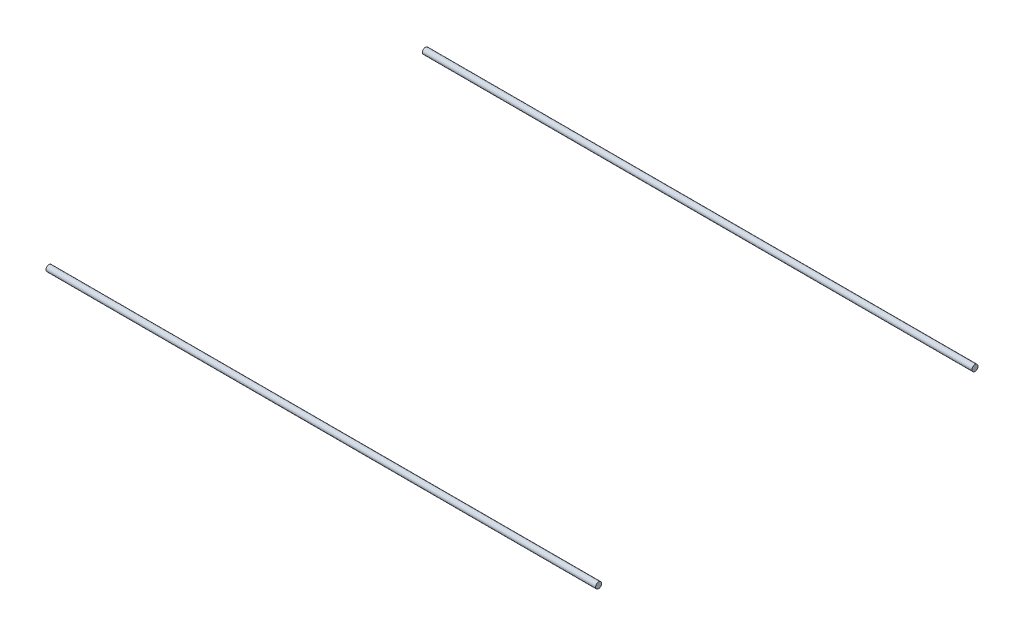
from build123d import *

# Parameters (mm, degrees)
BOSS_EXTRUDE1_DEPTH   = 265
BOSS_EXTRUDE1_2_DEPTH = 265
BOSS_EXTRUDE2_DEPTH   = 335
SKETCH16_R            = 4
BOSS_EXTRUDE3_DEPTH   = 730
BOSS_EXTRUDE3_2_DEPTH = 730


with BuildPart() as part:
    # Sketch13 → Boss-Extrude1 (new, symmetric)
    with BuildSketch(Plane.XY):
        with BuildLine():
            Line((356.00446543, 0.899999619), (355.484852164, 0))
            Line((355.484852164, 0), (356.00446543, -0.899999619))
            Line((356.00446543, -0.899999619), (356.00446543, -4.204465866))
            Line((356.00446543, -4.204465866), (360.049999564, -8.25))
            Line((360.049999564, -8.25), (362.59999928, -8.25))
            ThreePointArc((362.59999928, -8.25), (362.741420837, -8.191421273), (362.799999564, -8.049999716))
            Line((362.799999564, -8.049999716), (362.799999564, -4.649999613))
            ThreePointArc((362.799999564, -4.649999613), (362.975735606, -4.225735278), (363.39999994, -4.049999237))
            Line((363.39999994, -4.049999237), (364.300000043, -4.049999237))
            ThreePointArc((364.300000043, -4.049999237), (364.4414216, -4.108577964), (364.500000327, -4.249999521))
            Line((364.500000327, -4.249999521), (364.500000327, -4.349998953))
            ThreePointArc((364.500000327, -4.349998953), (364.558579054, -4.49142051), (364.700000611, -4.549999237))
            Line((364.700000611, -4.549999237), (364.799999716, -4.549999237))
            ThreePointArc((364.799999716, -4.549999237), (364.941421273, -4.608577964), (365, -4.749999521))
            Line((365, -4.749999521), (365, -13.000000346))
            ThreePointArc((365, -13.000000346), (364.414213664, -14.414213664), (363.000000346, -15))
            Line((363.000000346, -15), (354.749999945, -15))
            ThreePointArc((354.749999945, -15), (354.60857832, -14.941421245), (354.549999564, -14.799999619))
            Line((354.549999564, -14.799999619), (354.549999564, -14.69999942))
            ThreePointArc((354.549999564, -14.69999942), (354.49142109, -14.558578474), (354.350000144, -14.5))
            Line((354.350000144, -14.5), (354.250000374, -14.5))
            ThreePointArc((354.250000374, -14.5), (354.108578753, -14.441421247), (354.05, -14.299999626))
            Line((354.05, -14.299999626), (354.05, -13.399999434))
            ThreePointArc((354.05, -13.399999434), (354.225735989, -12.975735226), (354.650000197, -12.799999237))
            Line((354.650000197, -12.799999237), (358.049999924, -12.799999237))
            ThreePointArc((358.049999924, -12.799999237), (358.191421565, -12.741420475), (358.250000327, -12.599998834))
            Line((358.250000327, -12.599998834), (358.250000327, -10.049999237))
            Line((358.250000327, -10.049999237), (354.204466193, -6))
            Line((354.204466193, -6), (350.899999946, -6))
            Line((350.899999946, -6), (350, -5.484851837))
            Line((350, -5.484851837), (349.100000054, -6))
            Line((349.100000054, -6), (345.795533807, -6))
            Line((345.795533807, -6), (341.749999673, -10.049999237))
            Line((341.749999673, -10.049999237), (341.749999673, -12.599998834))
            ThreePointArc((341.749999673, -12.599998834), (341.808578435, -12.741420475), (341.950000076, -12.799999237))
            Line((341.950000076, -12.799999237), (345.349999803, -12.799999237))
            ThreePointArc((345.349999803, -12.799999237), (345.774264011, -12.975735226), (345.95, -13.399999434))
            Line((345.95, -13.399999434), (345.95, -14.299999626))
            ThreePointArc((345.95, -14.299999626), (345.891421247, -14.441421247), (345.749999626, -14.5))
            Line((345.749999626, -14.5), (345.649999856, -14.5))
            ThreePointArc((345.649999856, -14.5), (345.50857891, -14.558578474), (345.450000436, -14.69999942))
            Line((345.450000436, -14.69999942), (345.450000436, -14.799999619))
            ThreePointArc((345.450000436, -14.799999619), (345.39142168, -14.941421245), (345.250000055, -15))
            Line((345.250000055, -15), (336.999999654, -15))
            ThreePointArc((336.999999654, -15), (335.585786336, -14.414213664), (335, -13.000000346))
            Line((335, -13.000000346), (335, -4.749999521))
            ThreePointArc((335, -4.749999521), (335.058578727, -4.608577964), (335.200000284, -4.549999237))
            Line((335.200000284, -4.549999237), (335.299999389, -4.549999237))
            ThreePointArc((335.299999389, -4.549999237), (335.441420946, -4.49142051), (335.499999673, -4.349998953))
            Line((335.499999673, -4.349998953), (335.499999673, -4.249999521))
            ThreePointArc((335.499999673, -4.249999521), (335.5585784, -4.108577964), (335.699999957, -4.049999237))
            Line((335.699999957, -4.049999237), (336.60000006, -4.049999237))
            ThreePointArc((336.60000006, -4.049999237), (337.024264394, -4.225735278), (337.200000436, -4.649999613))
            Line((337.200000436, -4.649999613), (337.200000436, -8.049999716))
            ThreePointArc((337.200000436, -8.049999716), (337.258579163, -8.191421273), (337.40000072, -8.25))
            Line((337.40000072, -8.25), (339.950000436, -8.25))
            Line((339.950000436, -8.25), (343.99553457, -4.204465866))
            Line((343.99553457, -4.204465866), (343.99553457, -0.899999619))
            Line((343.99553457, -0.899999619), (344.515147836, 0))
            Line((344.515147836, 0), (343.99553457, 0.899999619))
            Line((343.99553457, 0.899999619), (343.99553457, 4.204465866))
            Line((343.99553457, 4.204465866), (339.950000436, 8.25))
            Line((339.950000436, 8.25), (337.40000072, 8.25))
            ThreePointArc((337.40000072, 8.25), (337.258579163, 8.191421273), (337.200000436, 8.049999716))
            Line((337.200000436, 8.049999716), (337.200000436, 4.649999613))
            ThreePointArc((337.200000436, 4.649999613), (337.024264394, 4.225735278), (336.60000006, 4.049999237))
            Line((336.60000006, 4.049999237), (335.699999957, 4.049999237))
            ThreePointArc((335.699999957, 4.049999237), (335.5585784, 4.108577964), (335.499999673, 4.249999521))
            Line((335.499999673, 4.249999521), (335.499999673, 4.349998953))
            ThreePointArc((335.499999673, 4.349998953), (335.441420946, 4.49142051), (335.299999389, 4.549999237))
            Line((335.299999389, 4.549999237), (335.200000284, 4.549999237))
            ThreePointArc((335.200000284, 4.549999237), (335.058578727, 4.608577964), (335, 4.749999521))
            Line((335, 4.749999521), (335, 13.000000346))
            ThreePointArc((335, 13.000000346), (335.585786336, 14.414213664), (336.999999654, 15))
            Line((336.999999654, 15), (345.250000055, 15))
            ThreePointArc((345.250000055, 15), (345.39142168, 14.941421245), (345.450000436, 14.799999619))
            Line((345.450000436, 14.799999619), (345.450000436, 14.69999942))
            ThreePointArc((345.450000436, 14.69999942), (345.50857891, 14.558578474), (345.649999856, 14.5))
            Line((345.649999856, 14.5), (345.749999626, 14.5))
            ThreePointArc((345.749999626, 14.5), (345.891421247, 14.441421247), (345.95, 14.299999626))
            Line((345.95, 14.299999626), (345.95, 13.399999434))
            ThreePointArc((345.95, 13.399999434), (345.774264011, 12.975735226), (345.349999803, 12.799999237))
            Line((345.349999803, 12.799999237), (341.950000076, 12.799999237))
            ThreePointArc((341.950000076, 12.799999237), (341.808578435, 12.741420475), (341.749999673, 12.599998834))
            Line((341.749999673, 12.599998834), (341.749999673, 10.049999237))
            Line((341.749999673, 10.049999237), (345.795533807, 6))
            Line((345.795533807, 6), (349.100000054, 6))
            Line((349.100000054, 6), (350, 5.484851837))
            Line((350, 5.484851837), (350.899999946, 6))
            Line((350.899999946, 6), (354.204466193, 6))
            Line((354.204466193, 6), (358.250000327, 10.049999237))
            Line((358.250000327, 10.049999237), (358.250000327, 12.599998834))
            ThreePointArc((358.250000327, 12.599998834), (358.191421565, 12.741420475), (358.049999924, 12.799999237))
            Line((358.049999924, 12.799999237), (354.650000197, 12.799999237))
            ThreePointArc((354.650000197, 12.799999237), (354.225735989, 12.975735226), (354.05, 13.399999434))
            Line((354.05, 13.399999434), (354.05, 14.299999626))
            ThreePointArc((354.05, 14.299999626), (354.108578753, 14.441421247), (354.250000374, 14.5))
            Line((354.250000374, 14.5), (354.350000144, 14.5))
            ThreePointArc((354.350000144, 14.5), (354.49142109, 14.558578474), (354.549999564, 14.69999942))
            Line((354.549999564, 14.69999942), (354.549999564, 14.799999619))
            ThreePointArc((354.549999564, 14.799999619), (354.60857832, 14.941421245), (354.749999945, 15))
            Line((354.749999945, 15), (363.000000346, 15))
            ThreePointArc((363.000000346, 15), (364.414213664, 14.414213664), (365, 13.000000346))
            Line((365, 13.000000346), (365, 4.749999521))
            ThreePointArc((365, 4.749999521), (364.941421273, 4.608577964), (364.799999716, 4.549999237))
            Line((364.799999716, 4.549999237), (364.700000611, 4.549999237))
            ThreePointArc((364.700000611, 4.549999237), (364.558579054, 4.49142051), (364.500000327, 4.349998953))
            Line((364.500000327, 4.349998953), (364.500000327, 4.249999521))
            ThreePointArc((364.500000327, 4.249999521), (364.4414216, 4.108577964), (364.300000043, 4.049999237))
            Line((364.300000043, 4.049999237), (363.39999994, 4.049999237))
            ThreePointArc((363.39999994, 4.049999237), (362.975735606, 4.225735278), (362.799999564, 4.649999613))
            Line((362.799999564, 4.649999613), (362.799999564, 8.049999716))
            ThreePointArc((362.799999564, 8.049999716), (362.741420837, 8.191421273), (362.59999928, 8.25))
            Line((362.59999928, 8.25), (360.049999564, 8.25))
            Line((360.049999564, 8.25), (356.00446543, 4.204465866))
            Line((356.00446543, 4.204465866), (356.00446543, 0.899999619))
        make_face()
        with BuildLine():
            Line((363.70000109, 12.700000408), (363.70000109, 10.499999626))
            ThreePointArc((363.70000109, 10.499999626), (363.407107874, 9.792892851), (362.7000011, 9.499999635))
            Line((362.7000011, 9.499999635), (360.500000318, 9.499999635))
            ThreePointArc((360.500000318, 9.499999635), (359.792893543, 9.792892851), (359.500000327, 10.499999626))
            Line((359.500000327, 10.499999626), (359.500000327, 12.700000408))
            ThreePointArc((359.500000327, 12.700000408), (359.792893543, 13.407107182), (360.500000318, 13.700000398))
            Line((360.500000318, 13.700000398), (362.7000011, 13.700000398))
            ThreePointArc((362.7000011, 13.700000398), (363.407107874, 13.407107182), (363.70000109, 12.700000408))
        make_face(mode=Mode.SUBTRACT)
        with BuildLine():
            Line((353.135929412, 4.518400903), (351.600129524, 3.280561767))
            ThreePointArc((351.600129524, 3.280561767), (350, 3.65), (348.399870476, 3.280561767))
            Line((348.399870476, 3.280561767), (346.864070588, 4.518400903))
            ThreePointArc((346.864070588, 4.518400903), (346.118997741, 3.897155561), (345.494663108, 3.154669473))
            Line((345.494663108, 3.154669473), (346.719438268, 1.600129597))
            ThreePointArc((346.719438268, 1.600129597), (346.35, 0), (346.719438268, -1.600129597))
            Line((346.719438268, -1.600129597), (345.494663108, -3.154669473))
            ThreePointArc((345.494663108, -3.154669473), (346.118997741, -3.897155561), (346.864070588, -4.518400903))
            Line((346.864070588, -4.518400903), (348.399870476, -3.280561767))
            ThreePointArc((348.399870476, -3.280561767), (350, -3.65), (351.600129524, -3.280561767))
            Line((351.600129524, -3.280561767), (353.135929412, -4.518400903))
            ThreePointArc((353.135929412, -4.518400903), (353.881002259, -3.897155561), (354.505336892, -3.154669473))
            Line((354.505336892, -3.154669473), (353.280561732, -1.600129597))
            ThreePointArc((353.280561732, -1.600129597), (353.65, 0), (353.280561732, 1.600129597))
            Line((353.280561732, 1.600129597), (354.505336892, 3.154669473))
            ThreePointArc((354.505336892, 3.154669473), (353.881002259, 3.897155561), (353.135929412, 4.518400903))
        make_face(mode=Mode.SUBTRACT)
        with BuildLine():
            Line((336.29999891, -12.700000408), (336.29999891, -10.499999626))
            ThreePointArc((336.29999891, -10.499999626), (336.592892126, -9.792892851), (337.2999989, -9.499999635))
            Line((337.2999989, -9.499999635), (339.499999682, -9.499999635))
            ThreePointArc((339.499999682, -9.499999635), (340.207106457, -9.792892851), (340.499999673, -10.499999626))
            Line((340.499999673, -10.499999626), (340.499999673, -12.700000408))
            ThreePointArc((340.499999673, -12.700000408), (340.207106457, -13.407107182), (339.499999682, -13.700000398))
            Line((339.499999682, -13.700000398), (337.2999989, -13.700000398))
            ThreePointArc((337.2999989, -13.700000398), (336.592892126, -13.407107182), (336.29999891, -12.700000408))
        make_face(mode=Mode.SUBTRACT)
        with BuildLine():
            Line((360.500000318, -13.700000398), (362.7000011, -13.700000398))
            ThreePointArc((362.7000011, -13.700000398), (363.407107874, -13.407107182), (363.70000109, -12.700000408))
            Line((363.70000109, -12.700000408), (363.70000109, -10.499999626))
            ThreePointArc((363.70000109, -10.499999626), (363.407107874, -9.792892851), (362.7000011, -9.499999635))
            Line((362.7000011, -9.499999635), (360.500000318, -9.499999635))
            ThreePointArc((360.500000318, -9.499999635), (359.792893543, -9.792892851), (359.500000327, -10.499999626))
            Line((359.500000327, -10.499999626), (359.500000327, -12.700000408))
            ThreePointArc((359.500000327, -12.700000408), (359.792893543, -13.407107182), (360.500000318, -13.700000398))
        make_face(mode=Mode.SUBTRACT)
        with BuildLine():
            Line((339.499999682, 13.700000398), (337.2999989, 13.700000398))
            ThreePointArc((337.2999989, 13.700000398), (336.592892126, 13.407107182), (336.29999891, 12.700000408))
            Line((336.29999891, 12.700000408), (336.29999891, 10.499999626))
            ThreePointArc((336.29999891, 10.499999626), (336.592892126, 9.792892851), (337.2999989, 9.499999635))
            Line((337.2999989, 9.499999635), (339.499999682, 9.499999635))
            ThreePointArc((339.499999682, 9.499999635), (340.207106457, 9.792892851), (340.499999673, 10.499999626))
            Line((340.499999673, 10.499999626), (340.499999673, 12.700000408))
            ThreePointArc((340.499999673, 12.700000408), (340.207106457, 13.407107182), (339.499999682, 13.700000398))
        make_face(mode=Mode.SUBTRACT)
    extrude(amount=BOSS_EXTRUDE1_DEPTH, both=True)



with BuildPart() as body_2:
    # Sketch13 → Boss-Extrude1 2 (new, symmetric)
    with BuildSketch(Plane.XY):
        with BuildLine():
            Line((-337.40000072, 8.25), (-339.950000436, 8.25))
            Line((-339.950000436, 8.25), (-343.99553457, 4.204465866))
            Line((-343.99553457, 4.204465866), (-343.99553457, 0.899999619))
            Line((-343.99553457, 0.899999619), (-344.515147836, 0))
            Line((-344.515147836, 0), (-343.99553457, -0.899999619))
            Line((-343.99553457, -0.899999619), (-343.99553457, -4.204465866))
            Line((-343.99553457, -4.204465866), (-339.950000436, -8.25))
            Line((-339.950000436, -8.25), (-337.40000072, -8.25))
            ThreePointArc((-337.40000072, -8.25), (-337.258579163, -8.191421273), (-337.200000436, -8.049999716))
            Line((-337.200000436, -8.049999716), (-337.200000436, -4.649999613))
            ThreePointArc((-337.200000436, -4.649999613), (-337.024264394, -4.225735278), (-336.60000006, -4.049999237))
            Line((-336.60000006, -4.049999237), (-335.699999957, -4.049999237))
            ThreePointArc((-335.699999957, -4.049999237), (-335.5585784, -4.108577964), (-335.499999673, -4.249999521))
            Line((-335.499999673, -4.249999521), (-335.499999673, -4.349998953))
            ThreePointArc((-335.499999673, -4.349998953), (-335.441420946, -4.49142051), (-335.299999389, -4.549999237))
            Line((-335.299999389, -4.549999237), (-335.200000284, -4.549999237))
            ThreePointArc((-335.200000284, -4.549999237), (-335.058578727, -4.608577964), (-335, -4.749999521))
            Line((-335, -4.749999521), (-335, -13.000000346))
            ThreePointArc((-335, -13.000000346), (-335.585786336, -14.414213664), (-336.999999654, -15))
            Line((-336.999999654, -15), (-345.250000055, -15))
            ThreePointArc((-345.250000055, -15), (-345.39142168, -14.941421245), (-345.450000436, -14.799999619))
            Line((-345.450000436, -14.799999619), (-345.450000436, -14.69999942))
            ThreePointArc((-345.450000436, -14.69999942), (-345.50857891, -14.558578474), (-345.649999856, -14.5))
            Line((-345.649999856, -14.5), (-345.749999626, -14.5))
            ThreePointArc((-345.749999626, -14.5), (-345.891421247, -14.441421247), (-345.95, -14.299999626))
            Line((-345.95, -14.299999626), (-345.95, -13.399999434))
            ThreePointArc((-345.95, -13.399999434), (-345.774264011, -12.975735226), (-345.349999803, -12.799999237))
            Line((-345.349999803, -12.799999237), (-341.950000076, -12.799999237))
            ThreePointArc((-341.950000076, -12.799999237), (-341.808578435, -12.741420475), (-341.749999673, -12.599998834))
            Line((-341.749999673, -12.599998834), (-341.749999673, -10.049999237))
            Line((-341.749999673, -10.049999237), (-345.795533807, -6))
            Line((-345.795533807, -6), (-349.100000054, -6))
            Line((-349.100000054, -6), (-350, -5.484851837))
            Line((-350, -5.484851837), (-350.899999946, -6))
            Line((-350.899999946, -6), (-354.204466193, -6))
            Line((-354.204466193, -6), (-358.250000327, -10.049999237))
            Line((-358.250000327, -10.049999237), (-358.250000327, -12.599998834))
            ThreePointArc((-358.250000327, -12.599998834), (-358.191421565, -12.741420475), (-358.049999924, -12.799999237))
            Line((-358.049999924, -12.799999237), (-354.650000197, -12.799999237))
            ThreePointArc((-354.650000197, -12.799999237), (-354.225735989, -12.975735226), (-354.05, -13.399999434))
            Line((-354.05, -13.399999434), (-354.05, -14.299999626))
            ThreePointArc((-354.05, -14.299999626), (-354.108578753, -14.441421247), (-354.250000374, -14.5))
            Line((-354.250000374, -14.5), (-354.350000144, -14.5))
            ThreePointArc((-354.350000144, -14.5), (-354.49142109, -14.558578474), (-354.549999564, -14.69999942))
            Line((-354.549999564, -14.69999942), (-354.549999564, -14.799999619))
            ThreePointArc((-354.549999564, -14.799999619), (-354.60857832, -14.941421245), (-354.749999945, -15))
            Line((-354.749999945, -15), (-363.000000346, -15))
            ThreePointArc((-363.000000346, -15), (-364.414213664, -14.414213664), (-365, -13.000000346))
            Line((-365, -13.000000346), (-365, -4.749999521))
            ThreePointArc((-365, -4.749999521), (-364.941421273, -4.608577964), (-364.799999716, -4.549999237))
            Line((-364.799999716, -4.549999237), (-364.700000611, -4.549999237))
            ThreePointArc((-364.700000611, -4.549999237), (-364.558579054, -4.49142051), (-364.500000327, -4.349998953))
            Line((-364.500000327, -4.349998953), (-364.500000327, -4.249999521))
            ThreePointArc((-364.500000327, -4.249999521), (-364.4414216, -4.108577964), (-364.300000043, -4.049999237))
            Line((-364.300000043, -4.049999237), (-363.39999994, -4.049999237))
            ThreePointArc((-363.39999994, -4.049999237), (-362.975735606, -4.225735278), (-362.799999564, -4.649999613))
            Line((-362.799999564, -4.649999613), (-362.799999564, -8.049999716))
            ThreePointArc((-362.799999564, -8.049999716), (-362.741420837, -8.191421273), (-362.59999928, -8.25))
            Line((-362.59999928, -8.25), (-360.049999564, -8.25))
            Line((-360.049999564, -8.25), (-356.00446543, -4.204465866))
            Line((-356.00446543, -4.204465866), (-356.00446543, -0.899999619))
            Line((-356.00446543, -0.899999619), (-355.484852164, 0))
            Line((-355.484852164, 0), (-356.00446543, 0.899999619))
            Line((-356.00446543, 0.899999619), (-356.00446543, 4.204465866))
            Line((-356.00446543, 4.204465866), (-360.049999564, 8.25))
            Line((-360.049999564, 8.25), (-362.59999928, 8.25))
            ThreePointArc((-362.59999928, 8.25), (-362.741420837, 8.191421273), (-362.799999564, 8.049999716))
            Line((-362.799999564, 8.049999716), (-362.799999564, 4.649999613))
            ThreePointArc((-362.799999564, 4.649999613), (-362.975735606, 4.225735278), (-363.39999994, 4.049999237))
            Line((-363.39999994, 4.049999237), (-364.300000043, 4.049999237))
            ThreePointArc((-364.300000043, 4.049999237), (-364.4414216, 4.108577964), (-364.500000327, 4.249999521))
            Line((-364.500000327, 4.249999521), (-364.500000327, 4.349998953))
            ThreePointArc((-364.500000327, 4.349998953), (-364.558579054, 4.49142051), (-364.700000611, 4.549999237))
            Line((-364.700000611, 4.549999237), (-364.799999716, 4.549999237))
            ThreePointArc((-364.799999716, 4.549999237), (-364.941421273, 4.608577964), (-365, 4.749999521))
            Line((-365, 4.749999521), (-365, 13.000000346))
            ThreePointArc((-365, 13.000000346), (-364.414213664, 14.414213664), (-363.000000346, 15))
            Line((-363.000000346, 15), (-354.749999945, 15))
            ThreePointArc((-354.749999945, 15), (-354.60857832, 14.941421245), (-354.549999564, 14.799999619))
            Line((-354.549999564, 14.799999619), (-354.549999564, 14.69999942))
            ThreePointArc((-354.549999564, 14.69999942), (-354.49142109, 14.558578474), (-354.350000144, 14.5))
            Line((-354.350000144, 14.5), (-354.250000374, 14.5))
            ThreePointArc((-354.250000374, 14.5), (-354.108578753, 14.441421247), (-354.05, 14.299999626))
            Line((-354.05, 14.299999626), (-354.05, 13.399999434))
            ThreePointArc((-354.05, 13.399999434), (-354.225735989, 12.975735226), (-354.650000197, 12.799999237))
            Line((-354.650000197, 12.799999237), (-358.049999924, 12.799999237))
            ThreePointArc((-358.049999924, 12.799999237), (-358.191421565, 12.741420475), (-358.250000327, 12.599998834))
            Line((-358.250000327, 12.599998834), (-358.250000327, 10.049999237))
            Line((-358.250000327, 10.049999237), (-354.204466193, 6))
            Line((-354.204466193, 6), (-350.899999946, 6))
            Line((-350.899999946, 6), (-350, 5.484851837))
            Line((-350, 5.484851837), (-349.100000054, 6))
            Line((-349.100000054, 6), (-345.795533807, 6))
            Line((-345.795533807, 6), (-341.749999673, 10.049999237))
            Line((-341.749999673, 10.049999237), (-341.749999673, 12.599998834))
            ThreePointArc((-341.749999673, 12.599998834), (-341.808578435, 12.741420475), (-341.950000076, 12.799999237))
            Line((-341.950000076, 12.799999237), (-345.349999803, 12.799999237))
            ThreePointArc((-345.349999803, 12.799999237), (-345.774264011, 12.975735226), (-345.95, 13.399999434))
            Line((-345.95, 13.399999434), (-345.95, 14.299999626))
            ThreePointArc((-345.95, 14.299999626), (-345.891421247, 14.441421247), (-345.749999626, 14.5))
            Line((-345.749999626, 14.5), (-345.649999856, 14.5))
            ThreePointArc((-345.649999856, 14.5), (-345.50857891, 14.558578474), (-345.450000436, 14.69999942))
            Line((-345.450000436, 14.69999942), (-345.450000436, 14.799999619))
            ThreePointArc((-345.450000436, 14.799999619), (-345.39142168, 14.941421245), (-345.250000055, 15))
            Line((-345.250000055, 15), (-336.999999654, 15))
            ThreePointArc((-336.999999654, 15), (-335.585786336, 14.414213664), (-335, 13.000000346))
            Line((-335, 13.000000346), (-335, 4.749999521))
            ThreePointArc((-335, 4.749999521), (-335.058578727, 4.608577964), (-335.200000284, 4.549999237))
            Line((-335.200000284, 4.549999237), (-335.299999389, 4.549999237))
            ThreePointArc((-335.299999389, 4.549999237), (-335.441420946, 4.49142051), (-335.499999673, 4.349998953))
            Line((-335.499999673, 4.349998953), (-335.499999673, 4.249999521))
            ThreePointArc((-335.499999673, 4.249999521), (-335.5585784, 4.108577964), (-335.699999957, 4.049999237))
            Line((-335.699999957, 4.049999237), (-336.60000006, 4.049999237))
            ThreePointArc((-336.60000006, 4.049999237), (-337.024264394, 4.225735278), (-337.200000436, 4.649999613))
            Line((-337.200000436, 4.649999613), (-337.200000436, 8.049999716))
            ThreePointArc((-337.200000436, 8.049999716), (-337.258579163, 8.191421273), (-337.40000072, 8.25))
        make_face()
        with BuildLine():
            Line((-336.29999891, -12.700000408), (-336.29999891, -10.499999626))
            ThreePointArc((-336.29999891, -10.499999626), (-336.592892126, -9.792892851), (-337.2999989, -9.499999635))
            Line((-337.2999989, -9.499999635), (-339.499999682, -9.499999635))
            ThreePointArc((-339.499999682, -9.499999635), (-340.207106457, -9.792892851), (-340.499999673, -10.499999626))
            Line((-340.499999673, -10.499999626), (-340.499999673, -12.700000408))
            ThreePointArc((-340.499999673, -12.700000408), (-340.207106457, -13.407107182), (-339.499999682, -13.700000398))
            Line((-339.499999682, -13.700000398), (-337.2999989, -13.700000398))
            ThreePointArc((-337.2999989, -13.700000398), (-336.592892126, -13.407107182), (-336.29999891, -12.700000408))
        make_face(mode=Mode.SUBTRACT)
        with BuildLine():
            Line((-346.719438268, 1.600129597), (-345.494663108, 3.154669473))
            ThreePointArc((-345.494663108, 3.154669473), (-346.118997741, 3.897155561), (-346.864070588, 4.518400903))
            Line((-346.864070588, 4.518400903), (-348.399870476, 3.280561767))
            ThreePointArc((-348.399870476, 3.280561767), (-350, 3.65), (-351.600129524, 3.280561767))
            Line((-351.600129524, 3.280561767), (-353.135929412, 4.518400903))
            ThreePointArc((-353.135929412, 4.518400903), (-353.881002259, 3.897155561), (-354.505336892, 3.154669473))
            Line((-354.505336892, 3.154669473), (-353.280561732, 1.600129597))
            ThreePointArc((-353.280561732, 1.600129597), (-353.65, 0), (-353.280561732, -1.600129597))
            Line((-353.280561732, -1.600129597), (-354.505336892, -3.154669473))
            ThreePointArc((-354.505336892, -3.154669473), (-353.881002259, -3.897155561), (-353.135929412, -4.518400903))
            Line((-353.135929412, -4.518400903), (-351.600129524, -3.280561767))
            ThreePointArc((-351.600129524, -3.280561767), (-350, -3.65), (-348.399870476, -3.280561767))
            Line((-348.399870476, -3.280561767), (-346.864070588, -4.518400903))
            ThreePointArc((-346.864070588, -4.518400903), (-346.118997741, -3.897155561), (-345.494663108, -3.154669473))
            Line((-345.494663108, -3.154669473), (-346.719438268, -1.600129597))
            ThreePointArc((-346.719438268, -1.600129597), (-346.35, 0), (-346.719438268, 1.600129597))
        make_face(mode=Mode.SUBTRACT)
        with BuildLine():
            Line((-336.29999891, 12.700000408), (-336.29999891, 10.499999626))
            ThreePointArc((-336.29999891, 10.499999626), (-336.592892126, 9.792892851), (-337.2999989, 9.499999635))
            Line((-337.2999989, 9.499999635), (-339.499999682, 9.499999635))
            ThreePointArc((-339.499999682, 9.499999635), (-340.207106457, 9.792892851), (-340.499999673, 10.499999626))
            Line((-340.499999673, 10.499999626), (-340.499999673, 12.700000408))
            ThreePointArc((-340.499999673, 12.700000408), (-340.207106457, 13.407107182), (-339.499999682, 13.700000398))
            Line((-339.499999682, 13.700000398), (-337.2999989, 13.700000398))
            ThreePointArc((-337.2999989, 13.700000398), (-336.592892126, 13.407107182), (-336.29999891, 12.700000408))
        make_face(mode=Mode.SUBTRACT)
        with BuildLine():
            Line((-359.500000327, -12.700000408), (-359.500000327, -10.499999626))
            ThreePointArc((-359.500000327, -10.499999626), (-359.792893543, -9.792892851), (-360.500000318, -9.499999635))
            Line((-360.500000318, -9.499999635), (-362.7000011, -9.499999635))
            ThreePointArc((-362.7000011, -9.499999635), (-363.407107874, -9.792892851), (-363.70000109, -10.499999626))
            Line((-363.70000109, -10.499999626), (-363.70000109, -12.700000408))
            ThreePointArc((-363.70000109, -12.700000408), (-363.407107874, -13.407107182), (-362.7000011, -13.700000398))
            Line((-362.7000011, -13.700000398), (-360.500000318, -13.700000398))
            ThreePointArc((-360.500000318, -13.700000398), (-359.792893543, -13.407107182), (-359.500000327, -12.700000408))
        make_face(mode=Mode.SUBTRACT)
        with BuildLine():
            Line((-363.70000109, 12.700000408), (-363.70000109, 10.499999626))
            ThreePointArc((-363.70000109, 10.499999626), (-363.407107874, 9.792892851), (-362.7000011, 9.499999635))
            Line((-362.7000011, 9.499999635), (-360.500000318, 9.499999635))
            ThreePointArc((-360.500000318, 9.499999635), (-359.792893543, 9.792892851), (-359.500000327, 10.499999626))
            Line((-359.500000327, 10.499999626), (-359.500000327, 12.700000408))
            ThreePointArc((-359.500000327, 12.700000408), (-359.792893543, 13.407107182), (-360.500000318, 13.700000398))
            Line((-360.500000318, 13.700000398), (-362.7000011, 13.700000398))
            ThreePointArc((-362.7000011, 13.700000398), (-363.407107874, 13.407107182), (-363.70000109, 12.700000408))
        make_face(mode=Mode.SUBTRACT)
    extrude(amount=BOSS_EXTRUDE1_2_DEPTH, both=True)


with BuildPart() as part_1:
    add(part.part)

    add(body_2.part)  # Boss-Extrude2 merges body 2
    # Sketch14 → Boss-Extrude2 (add, symmetric)
    # profile 1 of 2: a face of its own
    with BuildSketch(Plane(origin=(0, 0, 0), x_dir=(0, 0, -1), z_dir=(1, 0, 0))):
        with BuildLine():
            Line((-235.299999389, 4.549999237), (-235.200000284, 4.549999237))
            ThreePointArc((-235.200000284, 4.549999237), (-235.058578727, 4.608577964), (-235, 4.749999521))
            Line((-235, 4.749999521), (-235, 13.000000346))
            ThreePointArc((-235, 13.000000346), (-235.585786336, 14.414213664), (-236.999999654, 15))
            Line((-236.999999654, 15), (-245.250000055, 15))
            ThreePointArc((-245.250000055, 15), (-245.39142168, 14.941421245), (-245.450000436, 14.799999619))
            Line((-245.450000436, 14.799999619), (-245.450000436, 14.69999942))
            ThreePointArc((-245.450000436, 14.69999942), (-245.50857891, 14.558578474), (-245.649999856, 14.5))
            Line((-245.649999856, 14.5), (-245.749999626, 14.5))
            ThreePointArc((-245.749999626, 14.5), (-245.891421247, 14.441421247), (-245.95, 14.299999626))
            Line((-245.95, 14.299999626), (-245.95, 13.399999434))
            ThreePointArc((-245.95, 13.399999434), (-245.774264011, 12.975735226), (-245.349999803, 12.799999237))
            Line((-245.349999803, 12.799999237), (-241.950000076, 12.799999237))
            ThreePointArc((-241.950000076, 12.799999237), (-241.808578435, 12.741420475), (-241.749999673, 12.599998834))
            Line((-241.749999673, 12.599998834), (-241.749999673, 10.049999237))
            Line((-241.749999673, 10.049999237), (-245.795533807, 6))
            Line((-245.795533807, 6), (-249.100000054, 6))
            Line((-249.100000054, 6), (-250, 5.484851837))
            Line((-250, 5.484851837), (-250.899999946, 6))
            Line((-250.899999946, 6), (-254.204466193, 6))
            Line((-254.204466193, 6), (-258.250000327, 10.049999237))
            Line((-258.250000327, 10.049999237), (-258.250000327, 12.599998834))
            ThreePointArc((-258.250000327, 12.599998834), (-258.191421565, 12.741420475), (-258.049999924, 12.799999237))
            Line((-258.049999924, 12.799999237), (-254.650000197, 12.799999237))
            ThreePointArc((-254.650000197, 12.799999237), (-254.225735989, 12.975735226), (-254.05, 13.399999434))
            Line((-254.05, 13.399999434), (-254.05, 14.299999626))
            ThreePointArc((-254.05, 14.299999626), (-254.108578753, 14.441421247), (-254.250000374, 14.5))
            Line((-254.250000374, 14.5), (-254.350000144, 14.5))
            ThreePointArc((-254.350000144, 14.5), (-254.49142109, 14.558578474), (-254.549999564, 14.69999942))
            Line((-254.549999564, 14.69999942), (-254.549999564, 14.799999619))
            ThreePointArc((-254.549999564, 14.799999619), (-254.60857832, 14.941421245), (-254.749999945, 15))
            Line((-254.749999945, 15), (-263.000000346, 15))
            ThreePointArc((-263.000000346, 15), (-264.414213664, 14.414213664), (-265, 13.000000346))
            Line((-265, 13.000000346), (-265, 4.749999521))
            ThreePointArc((-265, 4.749999521), (-264.941421273, 4.608577964), (-264.799999716, 4.549999237))
            Line((-264.799999716, 4.549999237), (-264.700000611, 4.549999237))
            ThreePointArc((-264.700000611, 4.549999237), (-264.558579054, 4.49142051), (-264.500000327, 4.349998953))
            Line((-264.500000327, 4.349998953), (-264.500000327, 4.249999521))
            ThreePointArc((-264.500000327, 4.249999521), (-264.4414216, 4.108577964), (-264.300000043, 4.049999237))
            Line((-264.300000043, 4.049999237), (-263.39999994, 4.049999237))
            ThreePointArc((-263.39999994, 4.049999237), (-262.975735606, 4.225735278), (-262.799999564, 4.649999613))
            Line((-262.799999564, 4.649999613), (-262.799999564, 8.049999716))
            ThreePointArc((-262.799999564, 8.049999716), (-262.741420837, 8.191421273), (-262.59999928, 8.25))
            Line((-262.59999928, 8.25), (-260.049999564, 8.25))
            Line((-260.049999564, 8.25), (-256.00446543, 4.204465866))
            Line((-256.00446543, 4.204465866), (-256.00446543, 0.899999619))
            Line((-256.00446543, 0.899999619), (-255.484852164, 0))
            Line((-255.484852164, 0), (-256.00446543, -0.899999619))
            Line((-256.00446543, -0.899999619), (-256.00446543, -4.204465866))
            Line((-256.00446543, -4.204465866), (-260.049999564, -8.25))
            Line((-260.049999564, -8.25), (-262.59999928, -8.25))
            ThreePointArc((-262.59999928, -8.25), (-262.741420837, -8.191421273), (-262.799999564, -8.049999716))
            Line((-262.799999564, -8.049999716), (-262.799999564, -4.649999613))
            ThreePointArc((-262.799999564, -4.649999613), (-262.975735606, -4.225735278), (-263.39999994, -4.049999237))
            Line((-263.39999994, -4.049999237), (-264.300000043, -4.049999237))
            ThreePointArc((-264.300000043, -4.049999237), (-264.4414216, -4.108577964), (-264.500000327, -4.249999521))
            Line((-264.500000327, -4.249999521), (-264.500000327, -4.349998953))
            ThreePointArc((-264.500000327, -4.349998953), (-264.558579054, -4.49142051), (-264.700000611, -4.549999237))
            Line((-264.700000611, -4.549999237), (-264.799999716, -4.549999237))
            ThreePointArc((-264.799999716, -4.549999237), (-264.941421273, -4.608577964), (-265, -4.749999521))
            Line((-265, -4.749999521), (-265, -13.000000346))
            ThreePointArc((-265, -13.000000346), (-264.414213664, -14.414213664), (-263.000000346, -15))
            Line((-263.000000346, -15), (-254.749999945, -15))
            ThreePointArc((-254.749999945, -15), (-254.60857832, -14.941421245), (-254.549999564, -14.799999619))
            Line((-254.549999564, -14.799999619), (-254.549999564, -14.69999942))
            ThreePointArc((-254.549999564, -14.69999942), (-254.49142109, -14.558578474), (-254.350000144, -14.5))
            Line((-254.350000144, -14.5), (-254.250000374, -14.5))
            ThreePointArc((-254.250000374, -14.5), (-254.108578753, -14.441421247), (-254.05, -14.299999626))
            Line((-254.05, -14.299999626), (-254.05, -13.399999434))
            ThreePointArc((-254.05, -13.399999434), (-254.225735989, -12.975735226), (-254.650000197, -12.799999237))
            Line((-254.650000197, -12.799999237), (-258.049999924, -12.799999237))
            ThreePointArc((-258.049999924, -12.799999237), (-258.191421565, -12.741420475), (-258.250000327, -12.599998834))
            Line((-258.250000327, -12.599998834), (-258.250000327, -10.049999237))
            Line((-258.250000327, -10.049999237), (-254.204466193, -6))
            Line((-254.204466193, -6), (-250.899999946, -6))
            Line((-250.899999946, -6), (-250, -5.484851837))
            Line((-250, -5.484851837), (-249.100000054, -6))
            Line((-249.100000054, -6), (-245.795533807, -6))
            Line((-245.795533807, -6), (-241.749999673, -10.049999237))
            Line((-241.749999673, -10.049999237), (-241.749999673, -12.599998834))
            ThreePointArc((-241.749999673, -12.599998834), (-241.808578435, -12.741420475), (-241.950000076, -12.799999237))
            Line((-241.950000076, -12.799999237), (-245.349999803, -12.799999237))
            ThreePointArc((-245.349999803, -12.799999237), (-245.774264011, -12.975735226), (-245.95, -13.399999434))
            Line((-245.95, -13.399999434), (-245.95, -14.299999626))
            ThreePointArc((-245.95, -14.299999626), (-245.891421247, -14.441421247), (-245.749999626, -14.5))
            Line((-245.749999626, -14.5), (-245.649999856, -14.5))
            ThreePointArc((-245.649999856, -14.5), (-245.50857891, -14.558578474), (-245.450000436, -14.69999942))
            Line((-245.450000436, -14.69999942), (-245.450000436, -14.799999619))
            ThreePointArc((-245.450000436, -14.799999619), (-245.39142168, -14.941421245), (-245.250000055, -15))
            Line((-245.250000055, -15), (-236.999999654, -15))
            ThreePointArc((-236.999999654, -15), (-235.585786336, -14.414213664), (-235, -13.000000346))
            Line((-235, -13.000000346), (-235, -4.749999521))
            ThreePointArc((-235, -4.749999521), (-235.058578727, -4.608577964), (-235.200000284, -4.549999237))
            Line((-235.200000284, -4.549999237), (-235.299999389, -4.549999237))
            ThreePointArc((-235.299999389, -4.549999237), (-235.441420946, -4.49142051), (-235.499999673, -4.349998953))
            Line((-235.499999673, -4.349998953), (-235.499999673, -4.249999521))
            ThreePointArc((-235.499999673, -4.249999521), (-235.5585784, -4.108577964), (-235.699999957, -4.049999237))
            Line((-235.699999957, -4.049999237), (-236.60000006, -4.049999237))
            ThreePointArc((-236.60000006, -4.049999237), (-237.024264394, -4.225735278), (-237.200000436, -4.649999613))
            Line((-237.200000436, -4.649999613), (-237.200000436, -8.049999716))
            ThreePointArc((-237.200000436, -8.049999716), (-237.258579163, -8.191421273), (-237.40000072, -8.25))
            Line((-237.40000072, -8.25), (-239.950000436, -8.25))
            Line((-239.950000436, -8.25), (-243.99553457, -4.204465866))
            Line((-243.99553457, -4.204465866), (-243.99553457, -0.899999619))
            Line((-243.99553457, -0.899999619), (-244.515147836, 0))
            Line((-244.515147836, 0), (-243.99553457, 0.899999619))
            Line((-243.99553457, 0.899999619), (-243.99553457, 4.204465866))
            Line((-243.99553457, 4.204465866), (-239.950000436, 8.25))
            Line((-239.950000436, 8.25), (-237.40000072, 8.25))
            ThreePointArc((-237.40000072, 8.25), (-237.258579163, 8.191421273), (-237.200000436, 8.049999716))
            Line((-237.200000436, 8.049999716), (-237.200000436, 4.649999613))
            ThreePointArc((-237.200000436, 4.649999613), (-237.024264394, 4.225735278), (-236.60000006, 4.049999237))
            Line((-236.60000006, 4.049999237), (-235.699999957, 4.049999237))
            ThreePointArc((-235.699999957, 4.049999237), (-235.5585784, 4.108577964), (-235.499999673, 4.249999521))
            Line((-235.499999673, 4.249999521), (-235.499999673, 4.349998953))
            ThreePointArc((-235.499999673, 4.349998953), (-235.441420946, 4.49142051), (-235.299999389, 4.549999237))
        make_face()
        with BuildLine():
            Line((-246.864070588, 4.518400903), (-248.399870476, 3.280561767))
            ThreePointArc((-248.399870476, 3.280561767), (-250, 3.65), (-251.600129524, 3.280561767))
            Line((-251.600129524, 3.280561767), (-253.135929412, 4.518400903))
            ThreePointArc((-253.135929412, 4.518400903), (-253.881002259, 3.897155561), (-254.505336892, 3.154669473))
            Line((-254.505336892, 3.154669473), (-253.280561732, 1.600129597))
            ThreePointArc((-253.280561732, 1.600129597), (-253.65, 0), (-253.280561732, -1.600129597))
            Line((-253.280561732, -1.600129597), (-254.505336892, -3.154669473))
            ThreePointArc((-254.505336892, -3.154669473), (-253.881002259, -3.897155561), (-253.135929412, -4.518400903))
            Line((-253.135929412, -4.518400903), (-251.600129524, -3.280561767))
            ThreePointArc((-251.600129524, -3.280561767), (-250, -3.65), (-248.399870476, -3.280561767))
            Line((-248.399870476, -3.280561767), (-246.864070588, -4.518400903))
            ThreePointArc((-246.864070588, -4.518400903), (-246.118997741, -3.897155561), (-245.494663108, -3.154669473))
            Line((-245.494663108, -3.154669473), (-246.719438268, -1.600129597))
            ThreePointArc((-246.719438268, -1.600129597), (-246.35, 0), (-246.719438268, 1.600129597))
            Line((-246.719438268, 1.600129597), (-245.494663108, 3.154669473))
            ThreePointArc((-245.494663108, 3.154669473), (-246.118997741, 3.897155561), (-246.864070588, 4.518400903))
        make_face(mode=Mode.SUBTRACT)
        with BuildLine():
            Line((-260.500000318, -9.499999635), (-262.7000011, -9.499999635))
            ThreePointArc((-262.7000011, -9.499999635), (-263.407107874, -9.792892851), (-263.70000109, -10.499999626))
            Line((-263.70000109, -10.499999626), (-263.70000109, -12.700000408))
            ThreePointArc((-263.70000109, -12.700000408), (-263.407107874, -13.407107182), (-262.7000011, -13.700000398))
            Line((-262.7000011, -13.700000398), (-260.500000318, -13.700000398))
            ThreePointArc((-260.500000318, -13.700000398), (-259.792893543, -13.407107182), (-259.500000327, -12.700000408))
            Line((-259.500000327, -12.700000408), (-259.500000327, -10.499999626))
            ThreePointArc((-259.500000327, -10.499999626), (-259.792893543, -9.792892851), (-260.500000318, -9.499999635))
        make_face(mode=Mode.SUBTRACT)
        with BuildLine():
            Line((-259.500000327, 12.700000408), (-259.500000327, 10.499999626))
            ThreePointArc((-259.500000327, 10.499999626), (-259.792893543, 9.792892851), (-260.500000318, 9.499999635))
            Line((-260.500000318, 9.499999635), (-262.7000011, 9.499999635))
            ThreePointArc((-262.7000011, 9.499999635), (-263.407107874, 9.792892851), (-263.70000109, 10.499999626))
            Line((-263.70000109, 10.499999626), (-263.70000109, 12.700000408))
            ThreePointArc((-263.70000109, 12.700000408), (-263.407107874, 13.407107182), (-262.7000011, 13.700000398))
            Line((-262.7000011, 13.700000398), (-260.500000318, 13.700000398))
            ThreePointArc((-260.500000318, 13.700000398), (-259.792893543, 13.407107182), (-259.500000327, 12.700000408))
        make_face(mode=Mode.SUBTRACT)
        with BuildLine():
            Line((-236.29999891, 12.700000408), (-236.29999891, 10.499999626))
            ThreePointArc((-236.29999891, 10.499999626), (-236.592892126, 9.792892851), (-237.2999989, 9.499999635))
            Line((-237.2999989, 9.499999635), (-239.499999682, 9.499999635))
            ThreePointArc((-239.499999682, 9.499999635), (-240.207106457, 9.792892851), (-240.499999673, 10.499999626))
            Line((-240.499999673, 10.499999626), (-240.499999673, 12.700000408))
            ThreePointArc((-240.499999673, 12.700000408), (-240.207106457, 13.407107182), (-239.499999682, 13.700000398))
            Line((-239.499999682, 13.700000398), (-237.2999989, 13.700000398))
            ThreePointArc((-237.2999989, 13.700000398), (-236.592892126, 13.407107182), (-236.29999891, 12.700000408))
        make_face(mode=Mode.SUBTRACT)
        with BuildLine():
            Line((-239.499999682, -9.499999635), (-237.2999989, -9.499999635))
            ThreePointArc((-237.2999989, -9.499999635), (-236.592892126, -9.792892851), (-236.29999891, -10.499999626))
            Line((-236.29999891, -10.499999626), (-236.29999891, -12.700000408))
            ThreePointArc((-236.29999891, -12.700000408), (-236.592892126, -13.407107182), (-237.2999989, -13.700000398))
            Line((-237.2999989, -13.700000398), (-239.499999682, -13.700000398))
            ThreePointArc((-239.499999682, -13.700000398), (-240.207106457, -13.407107182), (-240.499999673, -12.700000408))
            Line((-240.499999673, -12.700000408), (-240.499999673, -10.499999626))
            ThreePointArc((-240.499999673, -10.499999626), (-240.207106457, -9.792892851), (-239.499999682, -9.499999635))
        make_face(mode=Mode.SUBTRACT)
    # profile 2 of 2: a face of its own
    with BuildSketch(Plane(origin=(0, 0, 0), x_dir=(0, 0, -1), z_dir=(1, 0, 0))):
        with BuildLine():
            Line((264.700000611, 4.549999237), (264.799999716, 4.549999237))
            ThreePointArc((264.799999716, 4.549999237), (264.941421273, 4.608577964), (265, 4.749999521))
            Line((265, 4.749999521), (265, 13.000000346))
            ThreePointArc((265, 13.000000346), (264.414213664, 14.414213664), (263.000000346, 15))
            Line((263.000000346, 15), (254.749999945, 15))
            ThreePointArc((254.749999945, 15), (254.60857832, 14.941421245), (254.549999564, 14.799999619))
            Line((254.549999564, 14.799999619), (254.549999564, 14.69999942))
            ThreePointArc((254.549999564, 14.69999942), (254.49142109, 14.558578474), (254.350000144, 14.5))
            Line((254.350000144, 14.5), (254.250000374, 14.5))
            ThreePointArc((254.250000374, 14.5), (254.108578753, 14.441421247), (254.05, 14.299999626))
            Line((254.05, 14.299999626), (254.05, 13.399999434))
            ThreePointArc((254.05, 13.399999434), (254.225735989, 12.975735226), (254.650000197, 12.799999237))
            Line((254.650000197, 12.799999237), (258.049999924, 12.799999237))
            ThreePointArc((258.049999924, 12.799999237), (258.191421565, 12.741420475), (258.250000327, 12.599998834))
            Line((258.250000327, 12.599998834), (258.250000327, 10.049999237))
            Line((258.250000327, 10.049999237), (254.204466193, 6))
            Line((254.204466193, 6), (250.899999946, 6))
            Line((250.899999946, 6), (250, 5.484851837))
            Line((250, 5.484851837), (249.100000054, 6))
            Line((249.100000054, 6), (245.795533807, 6))
            Line((245.795533807, 6), (241.749999673, 10.049999237))
            Line((241.749999673, 10.049999237), (241.749999673, 12.599998834))
            ThreePointArc((241.749999673, 12.599998834), (241.808578435, 12.741420475), (241.950000076, 12.799999237))
            Line((241.950000076, 12.799999237), (245.349999803, 12.799999237))
            ThreePointArc((245.349999803, 12.799999237), (245.774264011, 12.975735226), (245.95, 13.399999434))
            Line((245.95, 13.399999434), (245.95, 14.299999626))
            ThreePointArc((245.95, 14.299999626), (245.891421247, 14.441421247), (245.749999626, 14.5))
            Line((245.749999626, 14.5), (245.649999856, 14.5))
            ThreePointArc((245.649999856, 14.5), (245.50857891, 14.558578474), (245.450000436, 14.69999942))
            Line((245.450000436, 14.69999942), (245.450000436, 14.799999619))
            ThreePointArc((245.450000436, 14.799999619), (245.39142168, 14.941421245), (245.250000055, 15))
            Line((245.250000055, 15), (236.999999654, 15))
            ThreePointArc((236.999999654, 15), (235.585786336, 14.414213664), (235, 13.000000346))
            Line((235, 13.000000346), (235, 4.749999521))
            ThreePointArc((235, 4.749999521), (235.058578727, 4.608577964), (235.200000284, 4.549999237))
            Line((235.200000284, 4.549999237), (235.299999389, 4.549999237))
            ThreePointArc((235.299999389, 4.549999237), (235.441420946, 4.49142051), (235.499999673, 4.349998953))
            Line((235.499999673, 4.349998953), (235.499999673, 4.249999521))
            ThreePointArc((235.499999673, 4.249999521), (235.5585784, 4.108577964), (235.699999957, 4.049999237))
            Line((235.699999957, 4.049999237), (236.60000006, 4.049999237))
            ThreePointArc((236.60000006, 4.049999237), (237.024264394, 4.225735278), (237.200000436, 4.649999613))
            Line((237.200000436, 4.649999613), (237.200000436, 8.049999716))
            ThreePointArc((237.200000436, 8.049999716), (237.258579163, 8.191421273), (237.40000072, 8.25))
            Line((237.40000072, 8.25), (239.950000436, 8.25))
            Line((239.950000436, 8.25), (243.99553457, 4.204465866))
            Line((243.99553457, 4.204465866), (243.99553457, 0.899999619))
            Line((243.99553457, 0.899999619), (244.515147836, 0))
            Line((244.515147836, 0), (243.99553457, -0.899999619))
            Line((243.99553457, -0.899999619), (243.99553457, -4.204465866))
            Line((243.99553457, -4.204465866), (239.950000436, -8.25))
            Line((239.950000436, -8.25), (237.40000072, -8.25))
            ThreePointArc((237.40000072, -8.25), (237.258579163, -8.191421273), (237.200000436, -8.049999716))
            Line((237.200000436, -8.049999716), (237.200000436, -4.649999613))
            ThreePointArc((237.200000436, -4.649999613), (237.024264394, -4.225735278), (236.60000006, -4.049999237))
            Line((236.60000006, -4.049999237), (235.699999957, -4.049999237))
            ThreePointArc((235.699999957, -4.049999237), (235.5585784, -4.108577964), (235.499999673, -4.249999521))
            Line((235.499999673, -4.249999521), (235.499999673, -4.349998953))
            ThreePointArc((235.499999673, -4.349998953), (235.441420946, -4.49142051), (235.299999389, -4.549999237))
            Line((235.299999389, -4.549999237), (235.200000284, -4.549999237))
            ThreePointArc((235.200000284, -4.549999237), (235.058578727, -4.608577964), (235, -4.749999521))
            Line((235, -4.749999521), (235, -13.000000346))
            ThreePointArc((235, -13.000000346), (235.585786336, -14.414213664), (236.999999654, -15))
            Line((236.999999654, -15), (245.250000055, -15))
            ThreePointArc((245.250000055, -15), (245.39142168, -14.941421245), (245.450000436, -14.799999619))
            Line((245.450000436, -14.799999619), (245.450000436, -14.69999942))
            ThreePointArc((245.450000436, -14.69999942), (245.50857891, -14.558578474), (245.649999856, -14.5))
            Line((245.649999856, -14.5), (245.749999626, -14.5))
            ThreePointArc((245.749999626, -14.5), (245.891421247, -14.441421247), (245.95, -14.299999626))
            Line((245.95, -14.299999626), (245.95, -13.399999434))
            ThreePointArc((245.95, -13.399999434), (245.774264011, -12.975735226), (245.349999803, -12.799999237))
            Line((245.349999803, -12.799999237), (241.950000076, -12.799999237))
            ThreePointArc((241.950000076, -12.799999237), (241.808578435, -12.741420475), (241.749999673, -12.599998834))
            Line((241.749999673, -12.599998834), (241.749999673, -10.049999237))
            Line((241.749999673, -10.049999237), (245.795533807, -6))
            Line((245.795533807, -6), (249.100000054, -6))
            Line((249.100000054, -6), (250, -5.484851837))
            Line((250, -5.484851837), (250.899999946, -6))
            Line((250.899999946, -6), (254.204466193, -6))
            Line((254.204466193, -6), (258.250000327, -10.049999237))
            Line((258.250000327, -10.049999237), (258.250000327, -12.599998834))
            ThreePointArc((258.250000327, -12.599998834), (258.191421565, -12.741420475), (258.049999924, -12.799999237))
            Line((258.049999924, -12.799999237), (254.650000197, -12.799999237))
            ThreePointArc((254.650000197, -12.799999237), (254.225735989, -12.975735226), (254.05, -13.399999434))
            Line((254.05, -13.399999434), (254.05, -14.299999626))
            ThreePointArc((254.05, -14.299999626), (254.108578753, -14.441421247), (254.250000374, -14.5))
            Line((254.250000374, -14.5), (254.350000144, -14.5))
            ThreePointArc((254.350000144, -14.5), (254.49142109, -14.558578474), (254.549999564, -14.69999942))
            Line((254.549999564, -14.69999942), (254.549999564, -14.799999619))
            ThreePointArc((254.549999564, -14.799999619), (254.60857832, -14.941421245), (254.749999945, -15))
            Line((254.749999945, -15), (263.000000346, -15))
            ThreePointArc((263.000000346, -15), (264.414213664, -14.414213664), (265, -13.000000346))
            Line((265, -13.000000346), (265, -4.749999521))
            ThreePointArc((265, -4.749999521), (264.941421273, -4.608577964), (264.799999716, -4.549999237))
            Line((264.799999716, -4.549999237), (264.700000611, -4.549999237))
            ThreePointArc((264.700000611, -4.549999237), (264.558579054, -4.49142051), (264.500000327, -4.349998953))
            Line((264.500000327, -4.349998953), (264.500000327, -4.249999521))
            ThreePointArc((264.500000327, -4.249999521), (264.4414216, -4.108577964), (264.300000043, -4.049999237))
            Line((264.300000043, -4.049999237), (263.39999994, -4.049999237))
            ThreePointArc((263.39999994, -4.049999237), (262.975735606, -4.225735278), (262.799999564, -4.649999613))
            Line((262.799999564, -4.649999613), (262.799999564, -8.049999716))
            ThreePointArc((262.799999564, -8.049999716), (262.741420837, -8.191421273), (262.59999928, -8.25))
            Line((262.59999928, -8.25), (260.049999564, -8.25))
            Line((260.049999564, -8.25), (256.00446543, -4.204465866))
            Line((256.00446543, -4.204465866), (256.00446543, -0.899999619))
            Line((256.00446543, -0.899999619), (255.484852164, 0))
            Line((255.484852164, 0), (256.00446543, 0.899999619))
            Line((256.00446543, 0.899999619), (256.00446543, 4.204465866))
            Line((256.00446543, 4.204465866), (260.049999564, 8.25))
            Line((260.049999564, 8.25), (262.59999928, 8.25))
            ThreePointArc((262.59999928, 8.25), (262.741420837, 8.191421273), (262.799999564, 8.049999716))
            Line((262.799999564, 8.049999716), (262.799999564, 4.649999613))
            ThreePointArc((262.799999564, 4.649999613), (262.975735606, 4.225735278), (263.39999994, 4.049999237))
            Line((263.39999994, 4.049999237), (264.300000043, 4.049999237))
            ThreePointArc((264.300000043, 4.049999237), (264.4414216, 4.108577964), (264.500000327, 4.249999521))
            Line((264.500000327, 4.249999521), (264.500000327, 4.349998953))
            ThreePointArc((264.500000327, 4.349998953), (264.558579054, 4.49142051), (264.700000611, 4.549999237))
        make_face()
        with BuildLine():
            Line((253.135929412, 4.518400903), (251.600129524, 3.280561767))
            ThreePointArc((251.600129524, 3.280561767), (250, 3.65), (248.399870476, 3.280561767))
            Line((248.399870476, 3.280561767), (246.864070588, 4.518400903))
            ThreePointArc((246.864070588, 4.518400903), (246.118997741, 3.897155561), (245.494663108, 3.154669473))
            Line((245.494663108, 3.154669473), (246.719438268, 1.600129597))
            ThreePointArc((246.719438268, 1.600129597), (246.35, 0), (246.719438268, -1.600129597))
            Line((246.719438268, -1.600129597), (245.494663108, -3.154669473))
            ThreePointArc((245.494663108, -3.154669473), (246.118997741, -3.897155561), (246.864070588, -4.518400903))
            Line((246.864070588, -4.518400903), (248.399870476, -3.280561767))
            ThreePointArc((248.399870476, -3.280561767), (250, -3.65), (251.600129524, -3.280561767))
            Line((251.600129524, -3.280561767), (253.135929412, -4.518400903))
            ThreePointArc((253.135929412, -4.518400903), (253.881002259, -3.897155561), (254.505336892, -3.154669473))
            Line((254.505336892, -3.154669473), (253.280561732, -1.600129597))
            ThreePointArc((253.280561732, -1.600129597), (253.65, 0), (253.280561732, 1.600129597))
            Line((253.280561732, 1.600129597), (254.505336892, 3.154669473))
            ThreePointArc((254.505336892, 3.154669473), (253.881002259, 3.897155561), (253.135929412, 4.518400903))
        make_face(mode=Mode.SUBTRACT)
        with BuildLine():
            Line((239.499999682, -9.499999635), (237.2999989, -9.499999635))
            ThreePointArc((237.2999989, -9.499999635), (236.592892126, -9.792892851), (236.29999891, -10.499999626))
            Line((236.29999891, -10.499999626), (236.29999891, -12.700000408))
            ThreePointArc((236.29999891, -12.700000408), (236.592892126, -13.407107182), (237.2999989, -13.700000398))
            Line((237.2999989, -13.700000398), (239.499999682, -13.700000398))
            ThreePointArc((239.499999682, -13.700000398), (240.207106457, -13.407107182), (240.499999673, -12.700000408))
            Line((240.499999673, -12.700000408), (240.499999673, -10.499999626))
            ThreePointArc((240.499999673, -10.499999626), (240.207106457, -9.792892851), (239.499999682, -9.499999635))
        make_face(mode=Mode.SUBTRACT)
        with BuildLine():
            Line((240.499999673, 12.700000408), (240.499999673, 10.499999626))
            ThreePointArc((240.499999673, 10.499999626), (240.207106457, 9.792892851), (239.499999682, 9.499999635))
            Line((239.499999682, 9.499999635), (237.2999989, 9.499999635))
            ThreePointArc((237.2999989, 9.499999635), (236.592892126, 9.792892851), (236.29999891, 10.499999626))
            Line((236.29999891, 10.499999626), (236.29999891, 12.700000408))
            ThreePointArc((236.29999891, 12.700000408), (236.592892126, 13.407107182), (237.2999989, 13.700000398))
            Line((237.2999989, 13.700000398), (239.499999682, 13.700000398))
            ThreePointArc((239.499999682, 13.700000398), (240.207106457, 13.407107182), (240.499999673, 12.700000408))
        make_face(mode=Mode.SUBTRACT)
        with BuildLine():
            Line((263.70000109, 12.700000408), (263.70000109, 10.499999626))
            ThreePointArc((263.70000109, 10.499999626), (263.407107874, 9.792892851), (262.7000011, 9.499999635))
            Line((262.7000011, 9.499999635), (260.500000318, 9.499999635))
            ThreePointArc((260.500000318, 9.499999635), (259.792893543, 9.792892851), (259.500000327, 10.499999626))
            Line((259.500000327, 10.499999626), (259.500000327, 12.700000408))
            ThreePointArc((259.500000327, 12.700000408), (259.792893543, 13.407107182), (260.500000318, 13.700000398))
            Line((260.500000318, 13.700000398), (262.7000011, 13.700000398))
            ThreePointArc((262.7000011, 13.700000398), (263.407107874, 13.407107182), (263.70000109, 12.700000408))
        make_face(mode=Mode.SUBTRACT)
        with BuildLine():
            Line((260.500000318, -9.499999635), (262.7000011, -9.499999635))
            ThreePointArc((262.7000011, -9.499999635), (263.407107874, -9.792892851), (263.70000109, -10.499999626))
            Line((263.70000109, -10.499999626), (263.70000109, -12.700000408))
            ThreePointArc((263.70000109, -12.700000408), (263.407107874, -13.407107182), (262.7000011, -13.700000398))
            Line((262.7000011, -13.700000398), (260.500000318, -13.700000398))
            ThreePointArc((260.500000318, -13.700000398), (259.792893543, -13.407107182), (259.500000327, -12.700000408))
            Line((259.500000327, -12.700000408), (259.500000327, -10.499999626))
            ThreePointArc((259.500000327, -10.499999626), (259.792893543, -9.792892851), (260.500000318, -9.499999635))
        make_face(mode=Mode.SUBTRACT)
    extrude(amount=BOSS_EXTRUDE2_DEPTH, both=True)


with BuildPart() as body_2_2:
    # Sketch16 → Boss-Extrude3 (new body)
    with BuildSketch(Plane.ZY.offset(365)):
        with Locations((250, 30.384042372)):
            Circle(SKETCH16_R)
    extrude(amount=-BOSS_EXTRUDE3_DEPTH)


with BuildPart() as body_3:
    # Sketch16 → Boss-Extrude3 2 (new body)
    with BuildSketch(Plane.ZY.offset(365)):
        with Locations((-250, 30.384042372)):
            Circle(SKETCH16_R)
    extrude(amount=-BOSS_EXTRUDE3_2_DEPTH)


solid = Compound([body_2_2.part, body_3.part])
